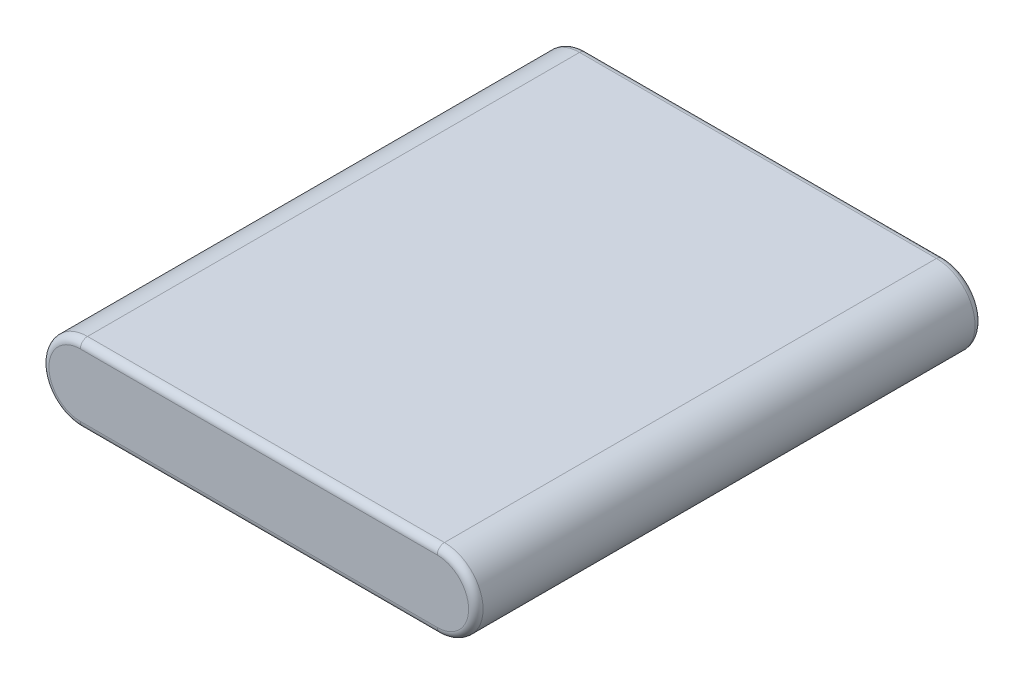
from build123d import *

# Parameters (mm, degrees)
EXTRUDE1_DEPTH = 52.5
FILLET1_R      = 1.5


with BuildPart() as part:
    # Sketch1 → Extrude1 (new body, symmetric)
    with BuildSketch(Plane.XY):
        with BuildLine():
            Line((37, -8), (-37, -8))
            ThreePointArc((-37, -8), (-45, 0), (-37, 8))
            Line((-37, 8), (37, 8))
            ThreePointArc((37, 8), (45, 0), (37, -8))
        make_face()
    extrude(amount=EXTRUDE1_DEPTH, both=True)

    # Fillet1
    fillet1_edges = [part.edges().sort_by_distance(p)[0] for p in [
        (-45, 0, 52.5),
        (0, -8, 52.5),
        (45, 0, 52.5),
        (0, -8, -52.5),
        (-45, 0, -52.5),
        (0, 8, -52.5),
        (45, 0, -52.5),
        (0, 8, 52.5),
    ]]
    fillet(fillet1_edges, radius=FILLET1_R)


solid = part.part
